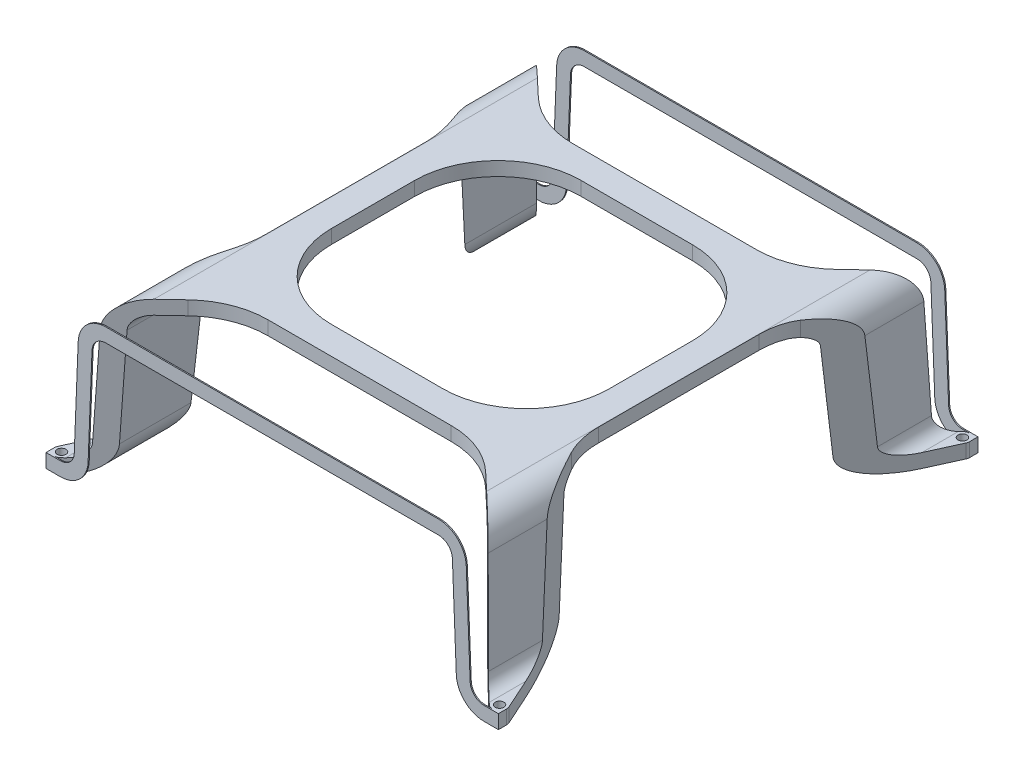
from build123d import *

# Parameters (mm, degrees)
BOSS_EXTRU_1_DEPTH      = 173
D_GAGEMENT_M31_D        = 3.2
D_GAGEMENT_M31_DEPTH    = 5
D_GAGEMENT_M31_TIP      = 0.96137699
ENL_V_MAT_EXTRU_1_DEPTH = 56


with BuildPart() as part:
    # Esquisse1 → Boss.-Extru.1 (new body)
    with BuildSketch(Plane.XY):
        with BuildLine():
            Line((-81.597369332, 0), (-76.402630668, 0))
            ThreePointArc((-76.402630668, 0), (-69.473365186, 2.789918178), (-66.41051645, 9.602944025))
            Line((-66.41051645, 9.602944025), (-64.996057109, 45.198527987))
            ThreePointArc((-64.996057109, 45.198527987), (-63.464632741, 48.605040911), (-60, 50))
            Line((-60, 50), (60, 50))
            ThreePointArc((60, 50), (63.464632741, 48.605040911), (64.996057109, 45.198527987))
            Line((64.996057109, 45.198527987), (66.41051645, 9.602944025))
            ThreePointArc((66.41051645, 9.602944025), (69.473365186, 2.789918178), (76.402630668, 0))
            Line((76.402630668, 0), (81.597369332, 0))
            Line((81.597369332, 0), (81.597369332, 5))
            Line((81.597369332, 5), (76.402630668, 5))
            ThreePointArc((76.402630668, 5), (72.937997927, 6.394959089), (71.406573559, 9.801472013))
            Line((71.406573559, 9.801472013), (69.992114218, 45.397055975))
            ThreePointArc((69.992114218, 45.397055975), (66.929265482, 52.210081822), (60, 55))
            Line((60, 55), (-60, 55))
            ThreePointArc((-60, 55), (-66.929265482, 52.210081822), (-69.992114218, 45.397055975))
            Line((-69.992114218, 45.397055975), (-71.406573559, 9.801472013))
            ThreePointArc((-71.406573559, 9.801472013), (-72.937997927, 6.394959089), (-76.402630668, 5))
            Line((-76.402630668, 5), (-81.597369332, 5))
            Line((-81.597369332, 5), (-81.597369332, 0))
        make_face()
    extrude(amount=BOSS_EXTRU_1_DEPTH)

    # Dégagement M31
    with Locations(Plane(origin=(0, 5, 0), x_dir=(1, 0, 0), z_dir=(0, 1, 0))):
        with Locations((-79, -170), (-79, -3), (79, -170), (79, -3)):
            Hole(D_GAGEMENT_M31_D / 2, depth=D_GAGEMENT_M31_DEPTH)
            with Locations((0, 0, -(D_GAGEMENT_M31_DEPTH + D_GAGEMENT_M31_TIP / 2))):  # 118° drill point
                Cone(0, D_GAGEMENT_M31_D / 2, D_GAGEMENT_M31_TIP, mode=Mode.SUBTRACT)

    # Esquisse4 → Enlèv. mat.-Extru.1 (cut, through all)
    with BuildSketch(Plane(origin=(0, 55, 0), x_dir=(1, 0, 0), z_dir=(0, 1, 0))):
        with BuildLine():
            ThreePointArc((-20.093103017, -131.5), (-41.306306452, -122.713203436), (-50.093103017, -101.5))
            Line((-50.093103017, -101.5), (-50.093103017, -71.5))
            ThreePointArc((-50.093103017, -71.5), (-41.306306452, -50.286796564), (-20.093103017, -41.5))
            Line((-20.093103017, -41.5), (20.093103017, -41.5))
            ThreePointArc((20.093103017, -41.5), (41.306306452, -50.286796564), (50.093103017, -71.5))
            Line((50.093103017, -71.5), (50.093103017, -101.5))
            ThreePointArc((50.093103017, -101.5), (41.306306452, -122.713203436), (20.093103017, -131.5))
            Line((20.093103017, -131.5), (-20.093103017, -131.5))
        make_face()
        with BuildLine():
            ThreePointArc((81.366251775, -168.928935118), (81.538932575, -169.4521416), (81.597369332, -170))
            Line((81.597369332, -170), (81.597369332, -3))
            ThreePointArc((81.597369332, -3), (81.538932575, -3.5478584), (81.366251775, -4.071064882))
            Line((81.366251775, -4.071064882), (62.762544981, -45.171333393))
            ThreePointArc((62.762544981, -45.171333393), (60.768056204, -51.214445653), (60.093103017, -57.542291215))
            Line((60.093103017, -57.542291215), (60.093103017, -115.457708785))
            ThreePointArc((60.093103017, -115.457708785), (60.768056204, -121.785554347), (62.762544981, -127.828666607))
            Line((62.762544981, -127.828666607), (81.366251775, -168.928935118))
        make_face()
        with BuildLine():
            Line((60, -0.402630668), (-60, -0.402630668))
            Line((-60, -0.402630668), (-60, -17.351236736))
            Line((-60, -17.351236736), (-53.668539182, -23.323392752))
            ThreePointArc((-53.668539182, -23.323392752), (-44.158310479, -29.381013096), (-33.083604671, -31.5))
            Line((-33.083604671, -31.5), (33.083604671, -31.5))
            ThreePointArc((33.083604671, -31.5), (44.158310479, -29.381013096), (53.668539182, -23.323392752))
            Line((53.668539182, -23.323392752), (60, -17.351236736))
            Line((60, -17.351236736), (60, -0.402630668))
        make_face()
        with BuildLine():
            Line((-60, -0.402630668), (-79, -0.402630668))
            ThreePointArc((-79, -0.402630668), (-78.041163293, -0.586090388), (-77.217777414, -1.110552965))
            Line((-77.217777414, -1.110552965), (-60, -17.351236736))
            Line((-60, -17.351236736), (-60, -0.402630668))
        make_face()
        with BuildLine():
            Line((79, -0.402630668), (60, -0.402630668))
            Line((60, -0.402630668), (60, -17.351236736))
            Line((60, -17.351236736), (77.217777414, -1.110552965))
            ThreePointArc((77.217777414, -1.110552965), (78.041163293, -0.586090388), (79, -0.402630668))
        make_face()
        with BuildLine():
            ThreePointArc((-81.597369332, -170), (-81.538932575, -169.4521416), (-81.366251775, -168.928935118))
            Line((-81.366251775, -168.928935118), (-62.762544981, -127.828666607))
            ThreePointArc((-62.762544981, -127.828666607), (-60.768056204, -121.785554347), (-60.093103017, -115.457708785))
            Line((-60.093103017, -115.457708785), (-60.093103017, -57.542291215))
            ThreePointArc((-60.093103017, -57.542291215), (-60.768056204, -51.214445653), (-62.762544981, -45.171333393))
            Line((-62.762544981, -45.171333393), (-81.366251775, -4.071064882))
            ThreePointArc((-81.366251775, -4.071064882), (-81.538932575, -3.5478584), (-81.597369332, -3))
            Line((-81.597369332, -3), (-81.597369332, -170))
        make_face()
        with BuildLine():
            Line((-60, -155.648763264), (-60, -172.597369332))
            Line((-60, -172.597369332), (60, -172.597369332))
            Line((60, -172.597369332), (60, -155.648763264))
            Line((60, -155.648763264), (53.668539182, -149.676607248))
            ThreePointArc((53.668539182, -149.676607248), (44.158310479, -143.618986904), (33.083604671, -141.5))
            Line((33.083604671, -141.5), (-33.083604671, -141.5))
            ThreePointArc((-33.083604671, -141.5), (-44.158310479, -143.618986904), (-53.668539182, -149.676607248))
            Line((-53.668539182, -149.676607248), (-60, -155.648763264))
        make_face()
        with BuildLine():
            Line((60, -155.648763264), (60, -172.597369332))
            Line((60, -172.597369332), (79, -172.597369332))
            ThreePointArc((79, -172.597369332), (78.041163293, -172.413909612), (77.217777414, -171.889447035))
            Line((77.217777414, -171.889447035), (60, -155.648763264))
        make_face()
        with BuildLine():
            ThreePointArc((-77.217777414, -171.889447035), (-78.041163293, -172.413909612), (-79, -172.597369332))
            Line((-79, -172.597369332), (-60, -172.597369332))
            Line((-60, -172.597369332), (-60, -155.648763264))
            Line((-60, -155.648763264), (-77.217777414, -171.889447035))
        make_face()
    extrude(amount=-ENL_V_MAT_EXTRU_1_DEPTH, mode=Mode.SUBTRACT)


solid = part.part
